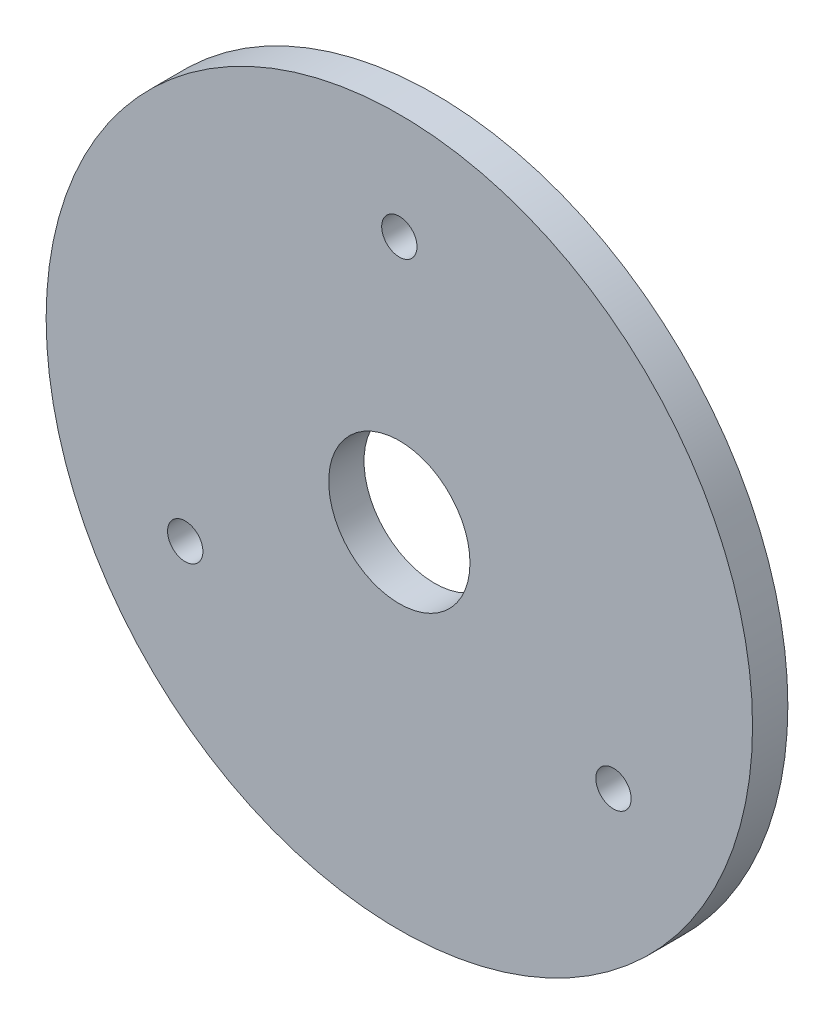
from build123d import *

# Parameters (mm, degrees)
SKETCH_1_R               = 20
EXTRUDE_1_DEPTH          = 2
SKETCH_2_R               = 1
CUT_EXTRUDE_1_DEPTH      = 2
PATTERN_CIRCULAR_1_COUNT = 3
SKETCH_3_R               = 4
CUT_EXTRUDE_2_DEPTH      = 2


with BuildPart() as part:
    # 草图1 → 凸台-拉伸1 (new body)
    with BuildSketch(Plane.XY):
        Circle(SKETCH_1_R)
    extrude(amount=EXTRUDE_1_DEPTH)

    # 草图2 → 切除-拉伸1 (cut)
    with BuildSketch(Plane.XY.offset(2)):
        with Locations((0, 14)):
            Circle(SKETCH_2_R)
    cut_extrude_1 = extrude(amount=-CUT_EXTRUDE_1_DEPTH, mode=Mode.SUBTRACT)

    # 阵列(圆周)1: 切除-拉伸1 ×3 about axis
    pattern_circular_1_axis = Axis((0, 0, 0), (0, 0, 1))
    for i in range(1, PATTERN_CIRCULAR_1_COUNT):
        add(cut_extrude_1.rotate(pattern_circular_1_axis, i * 360 / PATTERN_CIRCULAR_1_COUNT), mode=Mode.SUBTRACT)

    # 草图3 → 切除-拉伸2 (cut)
    with BuildSketch(Plane.XY.offset(2)):
        Circle(SKETCH_3_R)
    extrude(amount=-CUT_EXTRUDE_2_DEPTH, mode=Mode.SUBTRACT)


solid = part.part
